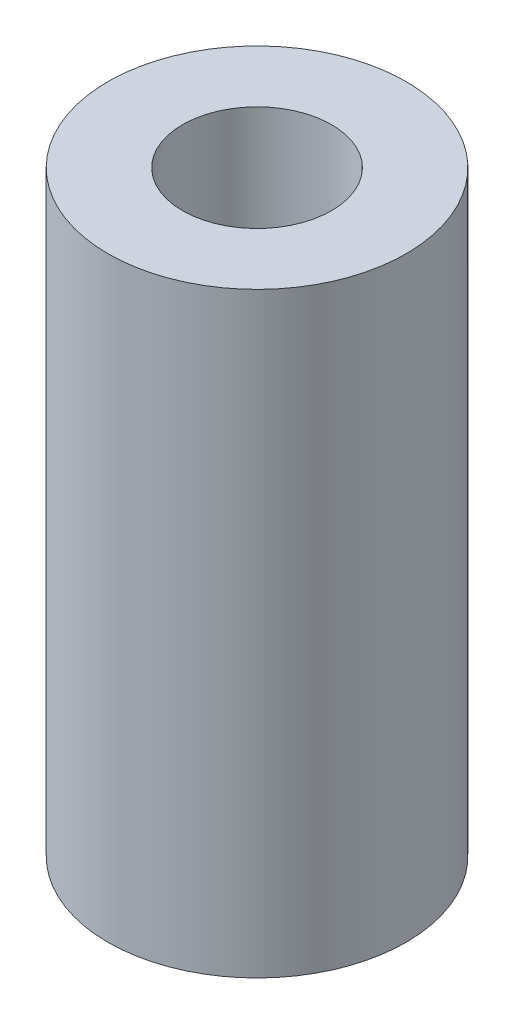
from build123d import *

# Parameters (mm, degrees)
SKETCH1_R           = 1.5875
SKETCH1_R_2         = 0.79375
BOSS_EXTRUDE1_DEPTH = 6.35


with BuildPart() as part:
    # Sketch1 → Boss-Extrude1 (new body)
    with BuildSketch(Plane(origin=(0, 0, 0), x_dir=(1, 0, 0), z_dir=(0, 1, 0))):
        Circle(SKETCH1_R)
        Circle(SKETCH1_R_2, mode=Mode.SUBTRACT)
    extrude(amount=BOSS_EXTRUDE1_DEPTH)


solid = part.part
